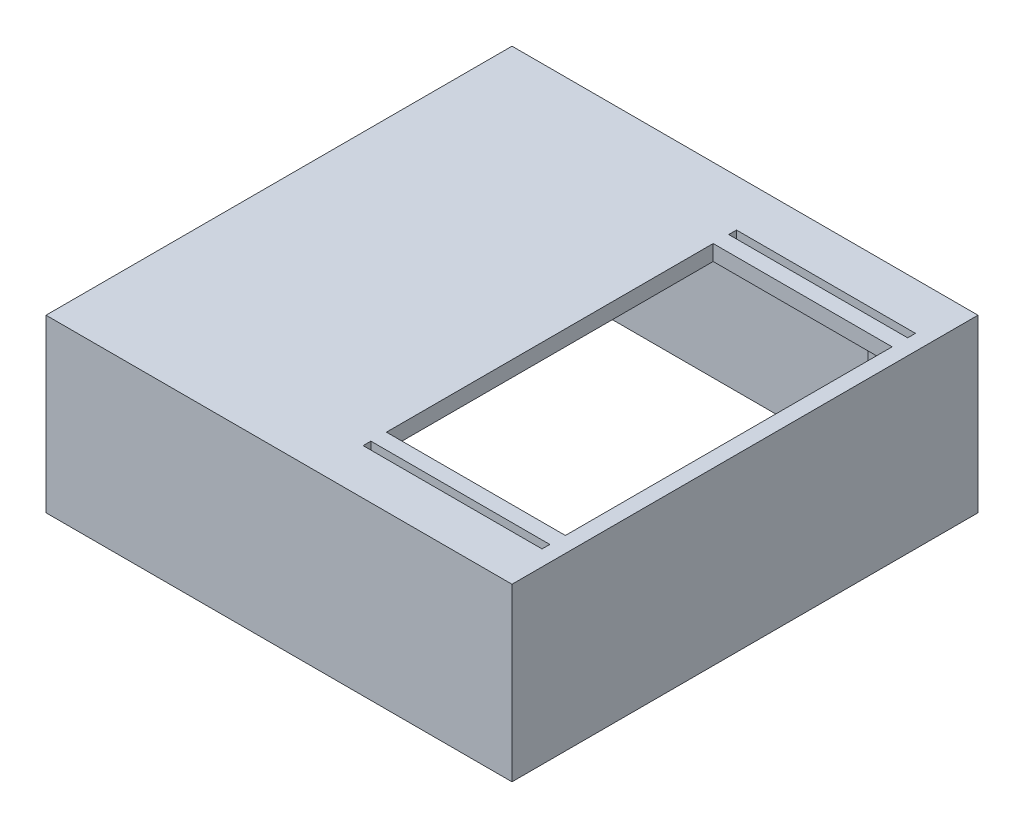
from build123d import *

# Parameters (mm, degrees)
SKETCH1_W            = 59.902393064
SKETCH1_H            = 59.902393064
SKETCH1_W_2          = 55.902393064
SKETCH1_H_2          = 55.902393064
SKETCH1_W_3          = 5
SKETCH1_H_3          = 5
SKETCH1_H_4          = 5.157397932
SKETCH1_W_4          = 4.976574335
SKETCH1_H_5          = 4.976574335
SKETCH1_W_5          = 4.983582997
SKETCH1_H_6          = 4.983582997
BOSS_EXTRUDE1_DEPTH  = 20
BOSS_EXTRUDE2_DEPTH  = 2
SKETCH3_W            = 23
SKETCH3_H            = 1
CUT_EXTRUDE1_DEPTH   = 2
SKETCH4_W            = 29.96
SKETCH4_H            = 59.9024
BOSS_EXTRUDE28_DEPTH = 2
SKETCH5_R            = 1.5
CUT_EXTRUDE2_DEPTH   = 5


with BuildPart() as part:
    # Sketch1 → Boss-Extrude1 (new body)
    with BuildSketch(Plane(origin=(0, 0, 0), x_dir=(1, 0, 0), z_dir=(0, 1, 0))):
        Rectangle(SKETCH1_W, SKETCH1_H)
        Rectangle(SKETCH1_W_2, SKETCH1_H_2, mode=Mode.SUBTRACT)
        with Locations((-25.451196532, 25.451196532)):
            Rectangle(SKETCH1_W_3, SKETCH1_H_3)
        with Locations((25.451196532, 25.372497566)):
            Rectangle(SKETCH1_W_3, SKETCH1_H_4)
        with Locations((25.462909364, -25.462909364)):
            Rectangle(SKETCH1_W_4, SKETCH1_H_5)
        with Locations((-25.459405034, -25.459405034)):
            Rectangle(SKETCH1_W_5, SKETCH1_H_6)
    extrude(amount=BOSS_EXTRUDE1_DEPTH)

    # Sketch2 → Boss-Extrude2 (add)
    with BuildSketch(Plane(origin=(0, 20, 0), x_dir=(1, 0, 0), z_dir=(0, 1, 0))):
        Polygon((4.951196532, -21.090411798), (4.951196532, -0.090411798), (4.951196532, 20.909588202), (4.951196532, 27.951196532), (0, 27.951196532), (0.003504331, -27.951196532), (4.951196532, -27.951196532), align=None)
        Polygon((29.951196532, -21.090411798), (27.951196532, -21.090411798), (27.951196532, -22.974622197), (22.974622197, -22.974622197), (22.974622197, -27.951196532), (4.951196532, -27.951196532), (0.003504331, -27.951196532), (0, -29.951196532), (29.951196532, -29.951196532), align=None)
        Polygon((27.951196532, -22.974622197), (27.951196532, -21.090411798), (4.951196532, -21.090411798), (4.951196532, -27.951196532), (22.974622197, -27.951196532), (22.974622197, -22.974622197), align=None)
        Polygon((27.951196532, 20.909588202), (27.951196532, -0.090411798), (27.951196532, -21.090411798), (29.951196532, -21.090411798), (29.951196532, 20.909588202), align=None)
        Polygon((27.951196532, 22.7937986), (27.951196532, 20.909588202), (29.951196532, 20.909588202), (29.951196532, 29.951196532), (0, 29.951196532), (0, 27.951196532), (4.951196532, 27.951196532), (22.951196532, 27.951196532), (22.951196532, 22.7937986), align=None)
        Polygon((4.951196532, 20.909588202), (27.951196532, 20.909588202), (27.951196532, 22.7937986), (22.951196532, 22.7937986), (22.951196532, 27.951196532), (4.951196532, 27.951196532), align=None)
    extrude(amount=BOSS_EXTRUDE2_DEPTH)

    # Sketch3 → Cut-Extrude1 (cut)
    with BuildSketch(Plane(origin=(0, 22, 0), x_dir=(1, 0, 0), z_dir=(0, 1, 0))):
        with Locations((16.451196532, -23.590411798)):
            Rectangle(SKETCH3_W, SKETCH3_H)
        with Locations((16.451196532, 23.409588202)):
            Rectangle(SKETCH3_W, SKETCH3_H)
    extrude(amount=-CUT_EXTRUDE1_DEPTH, mode=Mode.SUBTRACT)

    # Sketch4 → Boss-Extrude28 (add)
    with BuildSketch(Plane(origin=(0, 20, 0), x_dir=(1, 0, 0), z_dir=(0, 1, 0))):
        with Locations((-14.971196532, -3.468e-06)):
            Rectangle(SKETCH4_W, SKETCH4_H)
    extrude(amount=BOSS_EXTRUDE28_DEPTH)

    # Sketch5 → Cut-Extrude2 (cut)
    with BuildSketch(Plane.XZ):
        with Locations((-26.459405034, 26.459405034)):
            Circle(SKETCH5_R)
        with Locations((26.462909365, 26.462909365)):
            Circle(SKETCH5_R)
        with Locations((26.451196532, -26.372497566)):
            Circle(SKETCH5_R)
        with Locations((-26.451196532, -26.451196532)):
            Circle(SKETCH5_R)
    extrude(amount=-CUT_EXTRUDE2_DEPTH, mode=Mode.SUBTRACT)


solid = part.part
